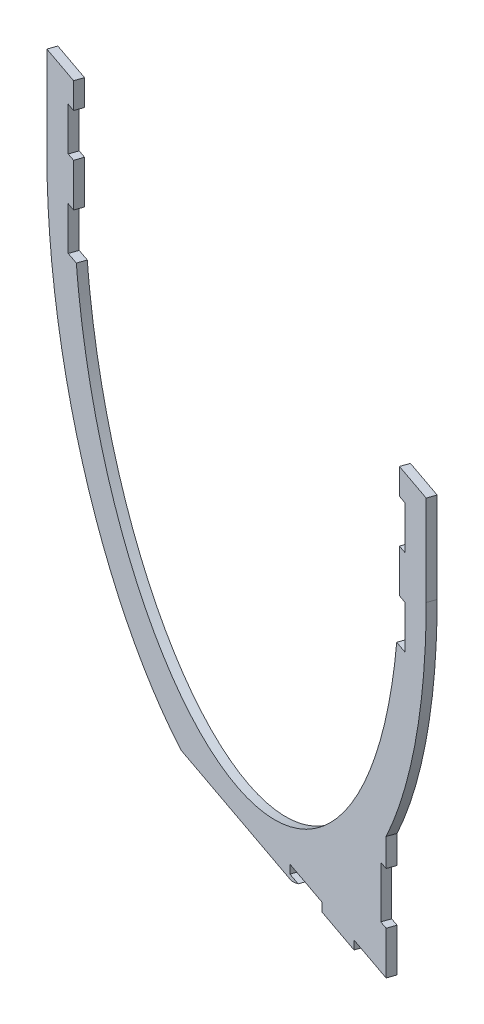
from build123d import *

# Parameters (mm, degrees)
BOSS_EXTRUDE1_DEPTH = 10


with BuildPart() as part:
    # Sketch4 → Boss-Extrude1 (new body)
    with BuildSketch(Plane(origin=(274.324104856, 0, -796.695049331), x_dir=(0.945518576, 0, 0.325568154), z_dir=(-0.325568154, 0, 0.945518576))):
        with BuildLine():
            Line((21.755705622, 335), (16.60929745, 335))
            add(Edge.make_bspline(
                [(-583.097886205, 335), (-536.728774067, 0), (-283.244294378, 0), (-29.759814689, 0), (16.60929745, 335)],
                knots=[4.896351675, 4.896351675, 4.896351675, 6.283185307, 6.283185307, 7.67001894, 7.67001894, 7.67001894], degree=2, weights=[1, 0.769066587, 1, 0.769066587, 1]))
            Line((-583.097886205, 335), (-588.244294378, 335))
            Line((-588.244294378, 335), (-598.244294378, 335))
            Line((-598.244294378, 335), (-598.244294378, 385))
            Line((-598.244294378, 385), (-588.244294378, 385))
            Line((-588.244294378, 385), (-588.244294378, 435))
            Line((-588.244294378, 435), (-598.244294378, 435))
            Line((-598.244294378, 435), (-598.244294378, 485))
            Line((-598.244294378, 485), (-588.244294378, 485))
            Line((-588.244294378, 485), (-588.244294378, 515))
            Line((-588.244294378, 515), (-638.244294378, 515))
            Line((-638.244294378, 515), (-638.244294378, 410))
            add(Edge.make_bspline(
                [(-638.244294378, 410), (-638.244294378, 69.353354952), (-386.783963771, -30)],
                knots=[1.570796327, 1.570796327, 1.570796327, 2.845629732, 2.845629732, 2.845629732], degree=2, weights=[1, 0.803635813, 1]))
            Line((-386.783963771, -30), (-179.704624985, -30))
            add(Edge.make_bspline(
                [(-179.704624985, -30), (-173.721030113, -27.635848868), (-167.805430637, -25)],
                knots=[3.437555575, 3.437555575, 3.437555575, 3.472794612, 3.472794612, 3.472794612], degree=2, weights=[1, 0.99984478, 1]))
            Line((-167.805430637, -25), (-183.244294378, -25))
            Line((-183.244294378, -25), (-183.244294378, -15))
            Line((-183.244294378, -15), (-123.244294378, -15))
            Line((-123.244294378, -15), (-123.244294378, -25))
            Line((-123.244294378, -25), (-63.244294378, -25))
            Line((-63.244294378, -25), (-63.244294378, -15))
            Line((-63.244294378, -15), (-3.244294378, -15))
            Line((-3.244294378, -15), (-3.244294378, 35))
            Line((-3.244294378, 35), (-13.244294378, 35))
            Line((-13.244294378, 35), (-13.244294378, 95))
            Line((-13.244294378, 95), (-3.244294378, 95))
            Line((-3.244294378, 95), (-3.244294378, 127.221118093))
            add(Edge.make_bspline(
                [(-3.244294378, 127.221118093), (71.755705622, 251.911018777), (71.755705622, 410)],
                knots=[4.050336884, 4.050336884, 4.050336884, 4.71238898, 4.71238898, 4.71238898], degree=2, weights=[1, 0.945709362, 1]))
            Line((71.755705622, 410), (71.755705622, 515))
            Line((71.755705622, 515), (21.755705622, 515))
            Line((21.755705622, 515), (21.755705622, 485))
            Line((21.755705622, 485), (31.755705622, 485))
            Line((31.755705622, 485), (31.755705622, 435))
            Line((31.755705622, 435), (21.755705622, 435))
            Line((21.755705622, 435), (21.755705622, 385))
            Line((21.755705622, 385), (31.755705622, 385))
            Line((31.755705622, 385), (31.755705622, 335))
            Line((31.755705622, 335), (21.755705622, 335))
        make_face()
    extrude(amount=BOSS_EXTRUDE1_DEPTH)


solid = part.part
